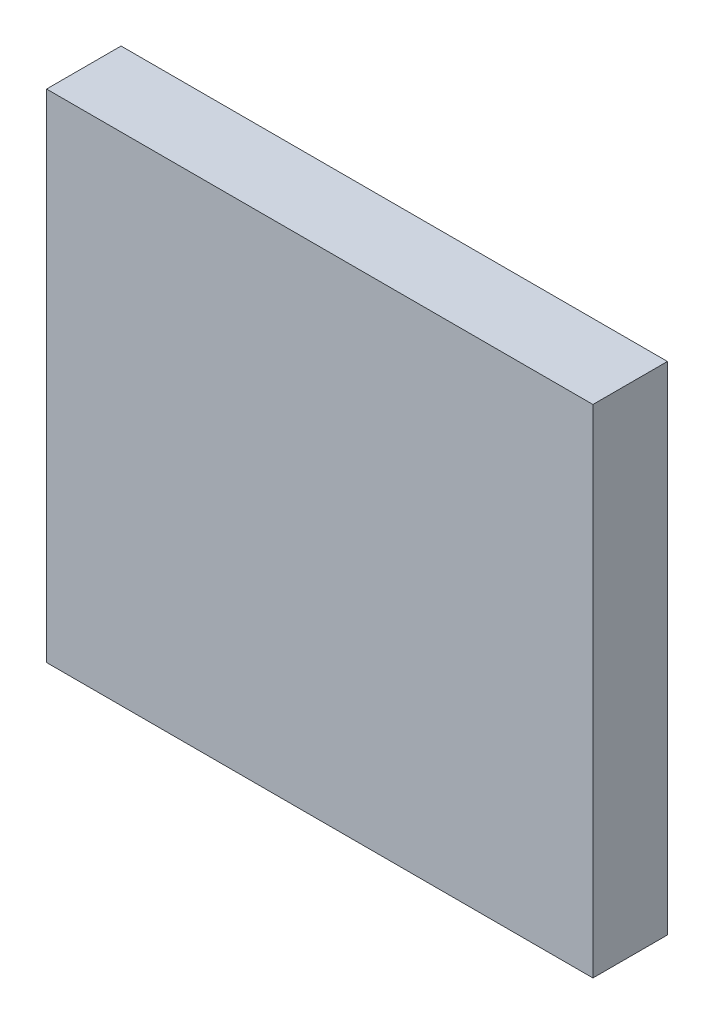
from build123d import *

# Parameters (mm, degrees)
SKETCH1_W           = 82.5
SKETCH1_H           = 75
BOSS_EXTRUDE1_DEPTH = 11.25
SKETCH2_W           = 76.5
SKETCH2_H           = 69
CUT_EXTRUDE1_DEPTH  = 9.25


with BuildPart() as part:
    # Sketch1 → Boss-Extrude1 (new body)
    with BuildSketch(Plane.XY):
        with Locations((41.25, 37.5)):
            Rectangle(SKETCH1_W, SKETCH1_H)
    extrude(amount=BOSS_EXTRUDE1_DEPTH)

    # Sketch2 → Cut-Extrude1 (cut)
    with BuildSketch(Plane(origin=(0, 0, 0), x_dir=(-1, 0, 0), z_dir=(0, 0, -1))):
        with Locations((-41.25, 37.5)):
            Rectangle(SKETCH2_W, SKETCH2_H)
    extrude(amount=-CUT_EXTRUDE1_DEPTH, mode=Mode.SUBTRACT)


solid = part.part
